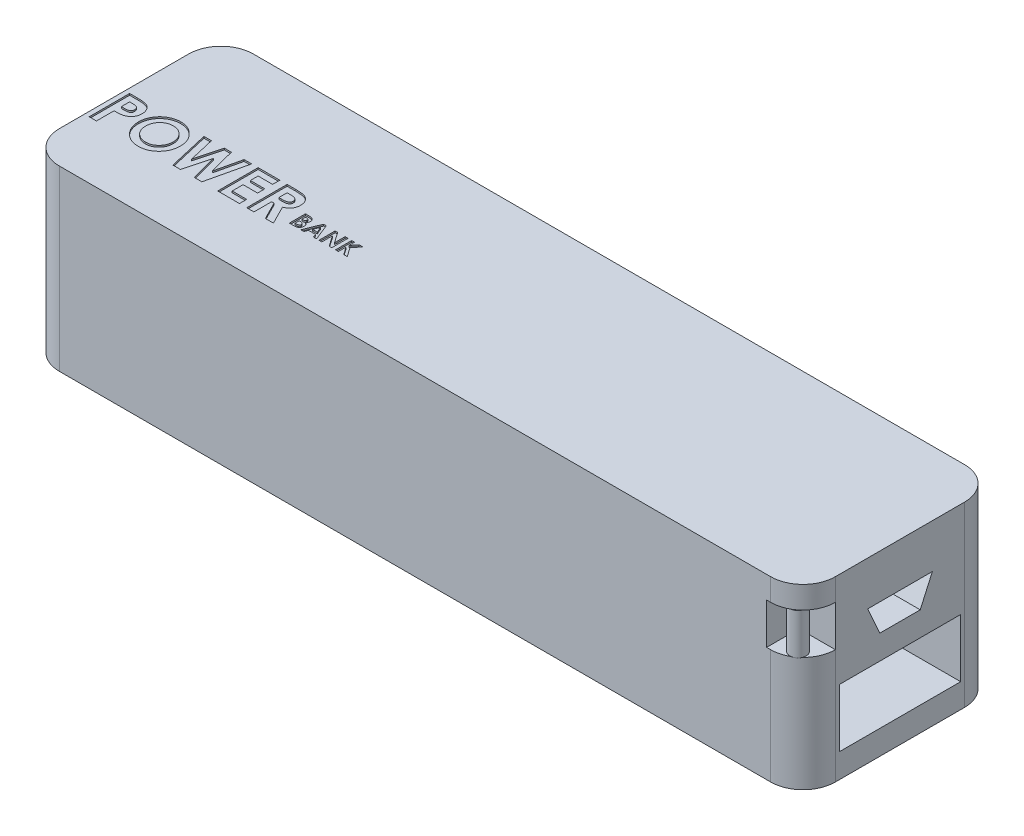
from build123d import *

# Parameters (mm, degrees)
BOSS_EXTRUDE1_DEPTH = 22
CUT_EXTRUDE1_DEPTH  = 0.2
CUT_EXTRUDE2_DEPTH  = 0.2
SKETCH4_W           = 15
SKETCH4_H           = 7.2
CUT_EXTRUDE3_DEPTH  = 10
CUT_EXTRUDE4_DEPTH  = 10
SKETCH6_W           = 4.5
SKETCH6_H           = 5.070723084
CUT_EXTRUDE5_DEPTH  = 4
SKETCH7_R           = 1
BOSS_EXTRUDE3_DEPTH = 5.070723


with BuildPart() as part:
    # Sketch1 → Boss-Extrude1 (new body)
    with BuildSketch(Plane(origin=(0, 0, 0), x_dir=(1, 0, 0), z_dir=(0, 1, 0))):
        with BuildLine():
            Line((-44, -12), (44, -12))
            ThreePointArc((44, -12), (46.828427125, -10.828427125), (48, -8))
            Line((48, -8), (48, 8))
            ThreePointArc((48, 8), (46.828427125, 10.828427125), (44, 12))
            Line((44, 12), (-44, 12))
            ThreePointArc((-44, 12), (-46.828427125, 10.828427125), (-48, 8))
            Line((-48, 8), (-48, -8))
            ThreePointArc((-48, -8), (-46.828427125, -10.828427125), (-44, -12))
        make_face()
    extrude(amount=BOSS_EXTRUDE1_DEPTH)

    # Sketch2 → Cut-Extrude1 (cut)
    with BuildSketch(Plane(origin=(0, 22, 0), x_dir=(1, 0, 0), z_dir=(0, 1, 0))):
        with BuildLine():
            Line((-47.423076923, 0.119421622), (-46.421474359, 0.119421622))
            add(Edge.make_bspline(
                [(-46.421474359, 0.119421622), (-46.356030947, 0.119128683), (-46.229776887, 0.118563543), (-46.047708145, 0.111710468), (-45.879740816, 0.099429341), (-45.725913491, 0.084251809), (-45.586289418, 0.062973501), (-45.460693748, 0.038579586), (-45.349100415, 0.008860699), (-45.250251039, -0.026415209), (-45.161536917, -0.068004126), (-45.077584745, -0.112299291), (-45.000291851, -0.165164009), (-44.925757029, -0.220900743), (-44.858241563, -0.284834005), (-44.793533435, -0.352708941), (-44.73437321, -0.427217416), (-44.680486762, -0.507457526), (-44.63160345, -0.591946776), (-44.588895719, -0.680836207), (-44.554253599, -0.774266478), (-44.525193168, -0.871633202), (-44.501851546, -0.972932135), (-44.48631462, -1.078786274), (-44.475761158, -1.188456505), (-44.474829961, -1.263098134), (-44.474358974, -1.300850814)],
                knots=[0, 0, 0, 0, 0.000196324, 0.000378751, 0.00054645, 0.000701527, 0.000842329, 0.000970009, 0.001085176, 0.001188463, 0.001284371, 0.001378936, 0.001472831, 0.001564984, 0.001657831, 0.001751361, 0.001846154, 0.001942828, 0.002041098, 0.002138763, 0.00223829, 0.002339695, 0.002443447, 0.002549829, 0.002660459, 0.00277368, 0.00277368, 0.00277368, 0.00277368], degree=3))
            add(Edge.make_bspline(
                [(-44.474358974, -1.300850814), (-44.475040433, -1.342615706), (-44.476379582, -1.424688851), (-44.489507563, -1.544998012), (-44.511934301, -1.659701904), (-44.541244875, -1.769767846), (-44.582116386, -1.87338501), (-44.628810168, -1.973025731), (-44.686258331, -2.065896392), (-44.75190204, -2.15315869), (-44.82359246, -2.235522111), (-44.903031518, -2.310608566), (-44.988705071, -2.378929917), (-45.080117185, -2.441202178), (-45.17761105, -2.49729973), (-45.281116318, -2.547747868), (-45.391339782, -2.590933105), (-45.468096086, -2.613518634), (-45.507011218, -2.624969404)],
                knots=[0, 0, 0, 0, 0.000125264, 0.00024616, 0.000362449, 0.000475684, 0.000587289, 0.000696151, 0.000805404, 0.000914178, 0.001023477, 0.001132583, 0.00124161, 0.0013519, 0.001464084, 0.001578762, 0.001697057, 0.00181871, 0.00181871, 0.00181871, 0.00181871], degree=3))
            add(Edge.make_bspline(
                [(-45.507011218, -2.624969404), (-45.532642962, -2.631346624), (-45.588169574, -2.645161734), (-45.680050865, -2.659187539), (-45.785934406, -2.672083405), (-45.906162588, -2.68316584), (-46.040804725, -2.690699313), (-46.189730447, -2.696582621), (-46.353007247, -2.700860393), (-46.466543477, -2.701012188), (-46.525641026, -2.701091199)],
                knots=[0, 0, 0, 0, 7.9203e-05, 0.000171578, 0.000278544, 0.00039924, 0.000533694, 0.000683053, 0.000846364, 0.00102365, 0.00102365, 0.00102365, 0.00102365], degree=3))
            Line((-46.525641026, -2.701091199), (-46.525641026, -4.880578378))
            Line((-46.525641026, -4.880578378), (-47.423076923, -4.880578378))
            Line((-47.423076923, -4.880578378), (-47.423076923, 0.119421622))
        make_face()
        with BuildLine():
            Line((-46.525641026, -1.803655302), (-46.208133013, -1.803655302))
            add(Edge.make_bspline(
                [(-46.208133013, -1.803655302), (-46.150357417, -1.803288959), (-46.044049463, -1.802614884), (-45.898870338, -1.792867369), (-45.782201601, -1.777980944), (-45.690031132, -1.756630368), (-45.617253816, -1.724228041), (-45.554487938, -1.686744651), (-45.500652042, -1.639347933), (-45.45403808, -1.585189073), (-45.416771622, -1.522957828), (-45.390929274, -1.453667514), (-45.374142594, -1.378773994), (-45.372592188, -1.326653061), (-45.371794872, -1.299849212)],
                knots=[0, 0, 0, 0, 0.000173303, 0.000318881, 0.000436167, 0.000526049, 0.000601409, 0.000674244, 0.000744535, 0.000815585, 0.000887902, 0.00096082, 0.001036651, 0.001116936, 0.001116936, 0.001116936, 0.001116936], degree=3))
            add(Edge.make_bspline(
                [(-45.371794872, -1.299849212), (-45.372583986, -1.276431038), (-45.374115058, -1.230994151), (-45.385362726, -1.165417452), (-45.403288275, -1.104286441), (-45.429261705, -1.04823955), (-45.4628392, -0.997372012), (-45.503776962, -0.951703865), (-45.551549679, -0.910257087), (-45.588433009, -0.888318675), (-45.607171474, -0.87717293)],
                knots=[0, 0, 0, 0, 7.0227e-05, 0.000136256, 0.000198999, 0.000260839, 0.000320843, 0.000381148, 0.000444376, 0.000509672, 0.000509672, 0.000509672, 0.000509672], degree=3))
            add(Edge.make_bspline(
                [(-45.607171474, -0.87717293), (-45.623044036, -0.86914572), (-45.656649503, -0.852150472), (-45.713882871, -0.832392253), (-45.779929303, -0.815724019), (-45.855234688, -0.801889546), (-45.939498611, -0.791152558), (-46.032706038, -0.782941448), (-46.134994131, -0.779639441), (-46.20612938, -0.778570939), (-46.243189103, -0.778014276)],
                knots=[0, 0, 0, 0, 5.3311e-05, 0.000112871, 0.000181134, 0.000257552, 0.000342405, 0.000435898, 0.00053814, 0.000649336, 0.000649336, 0.000649336, 0.000649336], degree=3))
            Line((-46.243189103, -0.778014276), (-46.525641026, -0.778014276))
            Line((-46.525641026, -0.778014276), (-46.525641026, -1.803655302))
        make_face(mode=Mode.SUBTRACT)
        with BuildLine():
            add(Edge.make_bspline(
                [(-41.227163462, 0.24762675), (-41.140232334, 0.245375947), (-40.968610598, 0.240932353), (-40.716216956, 0.203891528), (-40.472989015, 0.143538815), (-40.239036762, 0.059644178), (-40.014945985, -0.050064676), (-39.799926243, -0.182477429), (-39.594747724, -0.340093291), (-39.401512935, -0.519235346), (-39.222929139, -0.714044508), (-39.068186176, -0.923791205), (-38.936227054, -1.14304069), (-38.82685898, -1.372380448), (-38.743554836, -1.613398766), (-38.685096872, -1.86486677), (-38.647540526, -2.126712918), (-38.643220968, -2.304994455), (-38.641025641, -2.395602417)],
                knots=[0, 0, 0, 0, 0.000260694, 0.000514669, 0.000763423, 0.0010115, 0.001258772, 0.00151061, 0.001767833, 0.002033636, 0.002300239, 0.002559459, 0.002814199, 0.003066888, 0.003320296, 0.003577575, 0.003840476, 0.004112177, 0.004112177, 0.004112177, 0.004112177], degree=3))
            add(Edge.make_bspline(
                [(-38.641025641, -2.395602417), (-38.64336357, -2.485189436), (-38.647970533, -2.661723532), (-38.683563657, -2.921156665), (-38.743006061, -3.169930922), (-38.824897302, -3.40860941), (-38.932281852, -3.636036051), (-39.061667627, -3.853662933), (-39.216468873, -4.059470427), (-39.39103938, -4.253348088), (-39.583226357, -4.429333667), (-39.786782876, -4.584420654), (-40.000769038, -4.715835515), (-40.224871635, -4.823518054), (-40.459571244, -4.907086507), (-40.704288129, -4.966050124), (-40.959007147, -5.001883504), (-41.132228432, -5.006460375), (-41.220152244, -5.008783507)],
                knots=[0, 0, 0, 0, 0.000268698, 0.000529479, 0.000783835, 0.001035021, 0.001285045, 0.001537037, 0.001793248, 0.002056349, 0.002318643, 0.002573855, 0.002822938, 0.003070676, 0.003318415, 0.003568875, 0.003824694, 0.00408839, 0.00408839, 0.00408839, 0.00408839], degree=3))
            add(Edge.make_bspline(
                [(-41.220152244, -5.008783507), (-41.312110008, -5.006699543), (-41.492794446, -5.002604838), (-41.75722693, -4.963666068), (-42.010576099, -4.905010677), (-42.250713673, -4.817470653), (-42.480085249, -4.708038262), (-42.697005566, -4.573265712), (-42.901401725, -4.413375724), (-43.092101276, -4.232463142), (-43.264875531, -4.034505096), (-43.4173827, -3.825379975), (-43.546025881, -3.606685311), (-43.65080978, -3.378318751), (-43.733417196, -3.141699537), (-43.791687343, -2.89538659), (-43.826108909, -2.639970657), (-43.830903633, -2.466487049), (-43.833333333, -2.378575173)],
                knots=[0, 0, 0, 0, 0.000275703, 0.000541718, 0.000800204, 0.001054613, 0.00130683, 0.001561426, 0.001819079, 0.002084056, 0.002348822, 0.002606265, 0.00285947, 0.00310865, 0.00335889, 0.003610091, 0.003866767, 0.004130463, 0.004130463, 0.004130463, 0.004130463], degree=3))
            add(Edge.make_bspline(
                [(-43.833333333, -2.378575173), (-43.832570753, -2.319432665), (-43.831055249, -2.20189653), (-43.812799408, -2.027713976), (-43.786516245, -1.856931232), (-43.747644694, -1.69022921), (-43.700425694, -1.526431907), (-43.63924681, -1.367063986), (-43.569608684, -1.210422962), (-43.48824309, -1.05835896), (-43.397772417, -0.912271097), (-43.299060858, -0.772848493), (-43.191860203, -0.641776974), (-43.076515783, -0.518195189), (-42.952630104, -0.402915452), (-42.821832754, -0.294305817), (-42.681587027, -0.195251343), (-42.534962462, -0.103332921), (-42.382785693, -0.020212686), (-42.225676219, 0.050536772), (-42.066870805, 0.112321068), (-41.904248025, 0.161083967), (-41.739550671, 0.200800838), (-41.571019285, 0.227066286), (-41.400176454, 0.245321622), (-41.284971324, 0.24685655), (-41.227163462, 0.24762675)],
                knots=[0, 0, 0, 0, 0.000177354, 0.000352463, 0.00052487, 0.000695436, 0.000865629, 0.001035846, 0.001207105, 0.001379616, 0.001552781, 0.001722309, 0.001891725, 0.002060382, 0.002229038, 0.002399089, 0.002570014, 0.002743708, 0.00291805, 0.003089722, 0.003260295, 0.003428856, 0.003598674, 0.003768114, 0.003940232, 0.004113581, 0.004113581, 0.004113581, 0.004113581], degree=3))
        make_face()
        with BuildLine():
            add(Edge.make_bspline(
                [(-41.241185897, -0.649809148), (-41.299690535, -0.651378958), (-41.415155278, -0.654477137), (-41.584521028, -0.678081065), (-41.747118129, -0.715779222), (-41.902045242, -0.77038454), (-42.049973833, -0.839883253), (-42.191166134, -0.924032521), (-42.323666924, -1.025724883), (-42.449242973, -1.139500928), (-42.562680269, -1.26627359), (-42.662905699, -1.402132057), (-42.746778241, -1.546849448), (-42.81702202, -1.699081373), (-42.869900018, -1.860539638), (-42.90756343, -2.029959525), (-42.931365301, -2.207632952), (-42.934365556, -2.328752696), (-42.935897436, -2.390594404)],
                knots=[0, 0, 0, 0, 0.000175464, 0.000346295, 0.000511984, 0.000675438, 0.000838087, 0.001001615, 0.001167482, 0.001338346, 0.00150928, 0.001676958, 0.001843934, 0.002010219, 0.002179038, 0.002352535, 0.002530316, 0.002715786, 0.002715786, 0.002715786, 0.002715786], degree=3))
            add(Edge.make_bspline(
                [(-42.935897436, -2.390594404), (-42.933866397, -2.459128928), (-42.929885897, -2.593445238), (-42.901878615, -2.789382252), (-42.853960943, -2.974425316), (-42.784768758, -3.14766941), (-42.698952294, -3.311038282), (-42.592381867, -3.462529612), (-42.466783411, -3.603050461), (-42.370023379, -3.685092386), (-42.320913462, -3.726732225)],
                knots=[0, 0, 0, 0, 0.000205573, 0.000402888, 0.000592382, 0.000777632, 0.000961338, 0.00114473, 0.001331968, 0.001524943, 0.001524943, 0.001524943, 0.001524943], degree=3))
            add(Edge.make_bspline(
                [(-42.320913462, -3.726732225), (-42.280683064, -3.757494138), (-42.201128666, -3.818324894), (-42.074142526, -3.896291987), (-41.943371807, -3.963117563), (-41.807829679, -4.017111838), (-41.667802401, -4.059582827), (-41.523309174, -4.089324562), (-41.374554734, -4.107990073), (-41.27396001, -4.110220956), (-41.223157051, -4.111347609)],
                knots=[0, 0, 0, 0, 0.000151848, 0.000300274, 0.000446302, 0.000591935, 0.000737374, 0.000884702, 0.001034031, 0.001186393, 0.001186393, 0.001186393, 0.001186393], degree=3))
            add(Edge.make_bspline(
                [(-41.223157051, -4.111347609), (-41.165658402, -4.109764488), (-41.052528002, -4.106649648), (-40.886315087, -4.083336297), (-40.727078066, -4.04388169), (-40.573828383, -3.989755388), (-40.42700794, -3.919384059), (-40.287334289, -3.832624745), (-40.154562545, -3.730542736), (-40.029146478, -3.615272562), (-39.914510265, -3.488000504), (-39.814493985, -3.351417382), (-39.727954715, -3.208532531), (-39.659171657, -3.057323633), (-39.604204569, -2.899218029), (-39.566994455, -2.733515504), (-39.542991513, -2.560899146), (-39.539990412, -2.443427614), (-39.538461538, -2.383583186)],
                knots=[0, 0, 0, 0, 0.000172462, 0.000339324, 0.000502327, 0.000663893, 0.000826066, 0.000989781, 0.001156255, 0.001327796, 0.001500144, 0.001669222, 0.001834983, 0.002000357, 0.00216665, 0.002336241, 0.002509057, 0.002688523, 0.002688523, 0.002688523, 0.002688523], degree=3))
            add(Edge.make_bspline(
                [(-39.538461538, -2.383583186), (-39.540043312, -2.324082881), (-39.543156791, -2.206965603), (-39.566511175, -2.034793041), (-39.605715571, -1.869822043), (-39.660004408, -1.711783197), (-39.729328379, -1.560521563), (-39.815054501, -1.416569069), (-39.916881973, -1.28006488), (-40.032467241, -1.151939221), (-40.158274701, -1.034199948), (-40.29334158, -0.932023661), (-40.433888555, -0.843235717), (-40.58314046, -0.773682827), (-40.738043725, -0.718270186), (-40.899543578, -0.677463523), (-41.06825171, -0.654642956), (-41.18302734, -0.651434779), (-41.241185897, -0.649809148)],
                knots=[0, 0, 0, 0, 0.000178465, 0.000351282, 0.000520125, 0.000686418, 0.000851792, 0.001018414, 0.001188087, 0.00136185, 0.001535486, 0.00170416, 0.001869254, 0.002033236, 0.002197025, 0.002362213, 0.002532052, 0.002706515, 0.002706515, 0.002706515, 0.002706515], degree=3))
        make_face(mode=Mode.SUBTRACT)
        Polygon((-38.224358974, 0.119421622), (-37.297876603, 0.119421622), (-36.557692308, -3.07268575), (-35.709334936, 0.119421622), (-34.836939103, 0.119421622), (-33.993589744, -3.07268575), (-33.255408654, 0.119421622), (-32.326923077, 0.119421622), (-33.483774038, -4.880578378), (-34.421274038, -4.880578378), (-35.275641026, -1.648406904), (-36.135016026, -4.880578378), (-37.065504808, -4.880578378), align=None)
        Polygon((-31.525641026, 0.119421622), (-28.833333333, 0.119421622), (-28.833333333, -0.778014276), (-30.628205128, -0.778014276), (-30.628205128, -1.739552737), (-28.833333333, -1.739552737), (-28.833333333, -2.636988635), (-30.628205128, -2.636988635), (-30.628205128, -3.983142481), (-28.833333333, -3.983142481), (-28.833333333, -4.880578378), (-31.525641026, -4.880578378), align=None)
        with BuildLine():
            Line((-27.935897436, 0.119421622), (-26.890224359, 0.119421622))
            add(Edge.make_bspline(
                [(-26.890224359, 0.119421622), (-26.821105687, 0.11917629), (-26.688171011, 0.118704448), (-26.496486469, 0.111260034), (-26.320397856, 0.100900521), (-26.159644457, 0.08509163), (-26.014295045, 0.06413095), (-25.884203946, 0.039421778), (-25.769374963, 0.011260378), (-25.668839672, -0.023830948), (-25.578111542, -0.063413431), (-25.493540312, -0.10889443), (-25.413260214, -0.1597675), (-25.337807834, -0.217371248), (-25.266527472, -0.280669398), (-25.199284655, -0.349725666), (-25.137029585, -0.425125619), (-25.080147749, -0.506392826), (-25.028304534, -0.591884064), (-24.982486006, -0.681716713), (-24.945226302, -0.775953247), (-24.91230336, -0.873231742), (-24.888590031, -0.974942815), (-24.872097758, -1.080096291), (-24.86002276, -1.189062321), (-24.859328506, -1.263089004), (-24.858974359, -1.300850814)],
                knots=[0, 0, 0, 0, 0.000207341, 0.000398776, 0.000575402, 0.000736458, 0.000883205, 0.001015799, 0.001133619, 0.001237515, 0.001334841, 0.001430288, 0.001525314, 0.001619667, 0.00171474, 0.001811071, 0.001908535, 0.00200774, 0.002108399, 0.002208289, 0.002309842, 0.002412147, 0.002516126, 0.002622664, 0.002731397, 0.002844618, 0.002844618, 0.002844618, 0.002844618], degree=3))
            add(Edge.make_bspline(
                [(-24.858974359, -1.300850814), (-24.859894305, -1.34026547), (-24.861698151, -1.417550425), (-24.871414649, -1.53107572), (-24.889173355, -1.639688782), (-24.916071499, -1.743071605), (-24.946987421, -1.842510909), (-24.988097668, -1.936171975), (-25.034494644, -2.02541697), (-25.089598977, -2.108983488), (-25.150073291, -2.188727708), (-25.220403645, -2.261594335), (-25.296033714, -2.331499672), (-25.381214939, -2.394065088), (-25.472192452, -2.453521029), (-25.570773881, -2.507403945), (-25.67631585, -2.557068329), (-25.750517081, -2.58476462), (-25.788461538, -2.598927737)],
                knots=[0, 0, 0, 0, 0.000118257, 0.00023188, 0.000341546, 0.000447947, 0.000552157, 0.000653556, 0.000754365, 0.000853544, 0.000953514, 0.001054124, 0.001156939, 0.001262107, 0.001370733, 0.001482805, 0.001598862, 0.00172032, 0.00172032, 0.00172032, 0.00172032], degree=3))
            Line((-25.788461538, -2.598927737), (-24.634615385, -4.880578378))
            Line((-24.634615385, -4.880578378), (-25.632211538, -4.880578378))
            Line((-25.632211538, -4.880578378), (-26.733974359, -2.701091199))
            Line((-26.733974359, -2.701091199), (-27.038461538, -2.701091199))
            Line((-27.038461538, -2.701091199), (-27.038461538, -4.880578378))
            Line((-27.038461538, -4.880578378), (-27.935897436, -4.880578378))
            Line((-27.935897436, -4.880578378), (-27.935897436, 0.119421622))
        make_face()
        with BuildLine():
            Line((-27.038461538, -1.803655302), (-26.688902244, -1.803655302))
            add(Edge.make_bspline(
                [(-26.688902244, -1.803655302), (-26.646165714, -1.803173974), (-26.564334443, -1.802252335), (-26.446650327, -1.797977393), (-26.339765084, -1.787676893), (-26.243219712, -1.774662597), (-26.156528404, -1.759635713), (-26.080464415, -1.738101276), (-26.013855716, -1.715026581), (-25.957491621, -1.686350721), (-25.909335435, -1.653740048), (-25.867755649, -1.616693514), (-25.833363205, -1.573816867), (-25.805056469, -1.526275311), (-25.783036906, -1.473648352), (-25.766964312, -1.416513714), (-25.757982109, -1.354220562), (-25.756948676, -1.311229804), (-25.756410256, -1.288831584)],
                knots=[0, 0, 0, 0, 0.000128221, 0.000245515, 0.000353154, 0.000450185, 0.000537801, 0.000616775, 0.000687116, 0.000748932, 0.000805883, 0.000861198, 0.000915322, 0.000970118, 0.001026671, 0.001085968, 0.001147728, 0.001214902, 0.001214902, 0.001214902, 0.001214902], degree=3))
            add(Edge.make_bspline(
                [(-25.756410256, -1.288831584), (-25.757428188, -1.262332853), (-25.759427725, -1.210281008), (-25.77926935, -1.135344603), (-25.810852931, -1.065985833), (-25.85414537, -1.002518079), (-25.908666569, -0.946877863), (-25.971233946, -0.897830571), (-26.043197856, -0.859047642), (-26.109831021, -0.833466834), (-26.170451627, -0.818161574), (-26.225159811, -0.806756229), (-26.288512218, -0.798672933), (-26.360556674, -0.79009916), (-26.441109537, -0.784539502), (-26.530609868, -0.780482059), (-26.628800622, -0.77882196), (-26.697248903, -0.778291256), (-26.732972756, -0.778014276)],
                knots=[0, 0, 0, 0, 7.9354e-05, 0.000155877, 0.00023073, 0.000307128, 0.000385047, 0.000463582, 0.000544718, 0.000629358, 0.000676973, 0.000732171, 0.000796904, 0.000868468, 0.00094982, 0.001039053, 0.00113723, 0.001244406, 0.001244406, 0.001244406, 0.001244406], degree=3))
            Line((-26.732972756, -0.778014276), (-27.038461538, -0.778014276))
            Line((-27.038461538, -0.778014276), (-27.038461538, -1.803655302))
        make_face(mode=Mode.SUBTRACT)
    extrude(amount=-CUT_EXTRUDE1_DEPTH, mode=Mode.SUBTRACT)

    # Sketch3 → Cut-Extrude2 (cut)
    with BuildSketch(Plane(origin=(0, 22, 0), x_dir=(1, 0, 0), z_dir=(0, 1, 0))):
        with BuildLine():
            Line((-23.649577928, -3.896093236), (-23.649577928, -1.896093236))
            Line((-23.649577928, -1.896093236), (-23.329065108, -1.896093236))
            add(Edge.make_bspline(
                [(-23.329065108, -1.896093236), (-23.306627206, -1.896090675), (-23.263210292, -1.89608572), (-23.200571016, -1.898285406), (-23.142478377, -1.901130946), (-23.08911725, -1.904314443), (-23.040396808, -1.909800246), (-22.996391141, -1.915581682), (-22.957012324, -1.922553738), (-22.932666541, -1.928807888), (-22.921212544, -1.931750287)],
                knots=[0, 0, 0, 0, 6.7309e-05, 0.000130241, 0.000188002, 0.000241809, 0.000290565, 0.000335044, 0.000374963, 0.000410431, 0.000410431, 0.000410431, 0.000410431], degree=3))
            add(Edge.make_bspline(
                [(-22.921212544, -1.931750287), (-22.906172282, -1.935900594), (-22.876658459, -1.944044829), (-22.834385247, -1.960492463), (-22.794283209, -1.978775174), (-22.756401308, -1.999632328), (-22.720972153, -2.02331573), (-22.688130389, -2.050013337), (-22.657167699, -2.078653509), (-22.629183498, -2.110034439), (-22.603890391, -2.143194205), (-22.581915216, -2.178124118), (-22.562821605, -2.214290077), (-22.547541715, -2.252147205), (-22.536028606, -2.291521162), (-22.527607965, -2.332243813), (-22.52215025, -2.374444016), (-22.521634567, -2.403154193), (-22.5213728, -2.417727851)],
                knots=[0, 0, 0, 0, 4.6779e-05, 9.1795e-05, 0.000135895, 0.000178934, 0.000221381, 0.000263553, 0.000305788, 0.000347777, 0.000389524, 0.000430761, 0.00047144, 0.000512061, 0.000553007, 0.000594337, 0.000636725, 0.000680424, 0.000680424, 0.000680424, 0.000680424], degree=3))
            add(Edge.make_bspline(
                [(-22.5213728, -2.417727851), (-22.522057243, -2.436451177), (-22.523404486, -2.473305742), (-22.532010762, -2.52743843), (-22.548148872, -2.578601601), (-22.569265196, -2.627738173), (-22.597976795, -2.674664866), (-22.634434973, -2.719359367), (-22.678049226, -2.763197888), (-22.711503766, -2.789476124), (-22.728904851, -2.803144518)],
                knots=[0, 0, 0, 0, 5.6181e-05, 0.000110586, 0.000163812, 0.000216736, 0.000270674, 0.000328239, 0.00038943, 0.000455759, 0.000455759, 0.000455759, 0.000455759], degree=3))
            add(Edge.make_bspline(
                [(-22.728904851, -2.803144518), (-22.714803846, -2.810342959), (-22.687155677, -2.82445711), (-22.647903399, -2.84765656), (-22.611560075, -2.872332118), (-22.577962751, -2.897987301), (-22.54781617, -2.92570967), (-22.51987553, -2.953901823), (-22.495519276, -2.984179054), (-22.473739179, -3.015462225), (-22.454808273, -3.04820432), (-22.438321542, -3.082350044), (-22.424395791, -3.118016047), (-22.412603105, -3.155020817), (-22.403808117, -3.193491635), (-22.398073598, -3.233442258), (-22.393682891, -3.274736434), (-22.393341336, -3.302864996), (-22.393167672, -3.317166954)],
                knots=[0, 0, 0, 0, 4.7489e-05, 9.3113e-05, 0.000136672, 0.000179225, 0.000219785, 0.000259451, 0.000298182, 0.000336191, 0.00037371, 0.000411519, 0.000449834, 0.000488481, 0.00052794, 0.000568056, 0.000609516, 0.000652401, 0.000652401, 0.000652401, 0.000652401], degree=3))
            add(Edge.make_bspline(
                [(-22.393167672, -3.317166954), (-22.394294634, -3.344482875), (-22.39651869, -3.398390736), (-22.412779902, -3.477539857), (-22.440971677, -3.552580403), (-22.478827416, -3.623214129), (-22.525472971, -3.687396307), (-22.579101983, -3.743619337), (-22.63917453, -3.791210884), (-22.694598716, -3.823331486), (-22.742536272, -3.844887414), (-22.782242054, -3.858214648), (-22.824885222, -3.870560977), (-22.871246896, -3.879230824), (-22.920486604, -3.887166422), (-22.973084434, -3.892066024), (-23.028942083, -3.895386364), (-23.067307531, -3.895852848), (-23.087077928, -3.896093236)],
                knots=[0, 0, 0, 0, 8.1923e-05, 0.000161675, 0.000241156, 0.000321638, 0.000401375, 0.00047845, 0.000554036, 0.000630516, 0.000669975, 0.000711533, 0.000756055, 0.000803041, 0.000852904, 0.000905646, 0.000961427, 0.001020734, 0.001020734, 0.001020734, 0.001020734], degree=3))
            Line((-23.087077928, -3.896093236), (-23.649577928, -3.896093236))
        make_face()
        with BuildLine():
            Line((-23.290603569, -2.255067595), (-23.290603569, -2.690965031))
            Line((-23.290603569, -2.690965031), (-23.195251005, -2.690965031))
            add(Edge.make_bspline(
                [(-23.195251005, -2.690965031), (-23.182291735, -2.690852021), (-23.157274648, -2.690633863), (-23.12114012, -2.687824057), (-23.087540844, -2.683030355), (-23.056604256, -2.676341935), (-23.028042169, -2.667848616), (-23.002037047, -2.657629324), (-22.978703229, -2.645160677), (-22.95159473, -2.626588078), (-22.922939091, -2.599257666), (-22.897713855, -2.559773223), (-22.882856359, -2.514366265), (-22.881201635, -2.482341761), (-22.880347159, -2.465804775)],
                knots=[0, 0, 0, 0, 3.887e-05, 7.5037e-05, 0.000108636, 0.00014062, 0.000169899, 0.000197947, 0.000224295, 0.000249077, 0.000296395, 0.000341964, 0.000388335, 0.000437847, 0.000437847, 0.000437847, 0.000437847], degree=3))
            add(Edge.make_bspline(
                [(-22.880347159, -2.465804775), (-22.881030896, -2.450315139), (-22.882352874, -2.42036655), (-22.897312462, -2.378316065), (-22.920547659, -2.341050729), (-22.947980076, -2.315545654), (-22.973813027, -2.29812644), (-22.995932785, -2.286656629), (-23.02021088, -2.276388972), (-23.047117311, -2.26853807), (-23.076498426, -2.262647031), (-23.108211505, -2.258320767), (-23.142311265, -2.255376129), (-23.165864042, -2.255172646), (-23.178023441, -2.255067595)],
                knots=[0, 0, 0, 0, 4.6284e-05, 8.9488e-05, 0.000132169, 0.000176944, 0.000200613, 0.000225523, 0.000251565, 0.000279578, 0.000309436, 0.000341392, 0.000375562, 0.000412029, 0.000412029, 0.000412029, 0.000412029], degree=3))
            Line((-23.178023441, -2.255067595), (-23.290603569, -2.255067595))
        make_face(mode=Mode.SUBTRACT)
        with BuildLine():
            Line((-23.290603569, -3.024298364), (-23.290603569, -3.537118877))
            Line((-23.290603569, -3.537118877), (-23.187238185, -3.537118877))
            add(Edge.make_bspline(
                [(-23.187238185, -3.537118877), (-23.166802717, -3.53700213), (-23.127512979, -3.536777669), (-23.0712305, -3.534065649), (-23.020055655, -3.52917771), (-22.97412404, -3.523075512), (-22.9333653, -3.514807988), (-22.897917212, -3.504296891), (-22.867293648, -3.492732854), (-22.841678231, -3.478449895), (-22.820751903, -3.461828072), (-22.801868086, -3.44484017), (-22.786471398, -3.425243021), (-22.774289251, -3.403877874), (-22.763745625, -3.381275457), (-22.757386454, -3.356553152), (-22.752544804, -3.33044367), (-22.752278355, -3.312384306), (-22.752142031, -3.303144518)],
                knots=[0, 0, 0, 0, 6.1303e-05, 0.000117863, 0.000168971, 0.000215489, 0.000256819, 0.000293582, 0.000326317, 0.000354842, 0.000381126, 0.000406353, 0.000430881, 0.00045548, 0.00048005, 0.000505421, 0.000531833, 0.000559503, 0.000559503, 0.000559503, 0.000559503], degree=3))
            add(Edge.make_bspline(
                [(-22.752142031, -3.303144518), (-22.752442665, -3.292578675), (-22.75302822, -3.271999255), (-22.757810454, -3.241920236), (-22.766501336, -3.213839476), (-22.777447926, -3.187038912), (-22.792680687, -3.162478097), (-22.810784304, -3.139307076), (-22.832658094, -3.11831049), (-22.857256447, -3.098218388), (-22.88594799, -3.080626663), (-22.918746185, -3.065362726), (-22.955829209, -3.052614848), (-22.997311931, -3.042464979), (-23.043012494, -3.033850926), (-23.093264462, -3.028707385), (-23.147649318, -3.024881908), (-23.185360663, -3.024497299), (-23.20486639, -3.024298364)],
                knots=[0, 0, 0, 0, 3.1691e-05, 6.1726e-05, 9.1006e-05, 0.000119729, 0.000148313, 0.000177408, 0.000207722, 0.000239069, 0.000272534, 0.00030838, 0.000347405, 0.000389965, 0.000436407, 0.0004868, 0.000541407, 0.000599912, 0.000599912, 0.000599912, 0.000599912], degree=3))
            Line((-23.20486639, -3.024298364), (-23.290603569, -3.024298364))
        make_face(mode=Mode.SUBTRACT)
        Polygon((-21.418408056, -1.896093236), (-21.085475364, -1.896093236), (-20.277783056, -3.896093236), (-20.661196518, -3.896093236), (-20.816645236, -3.485836826), (-21.688039467, -3.485836826), (-21.843488185, -3.896093236), (-22.226501005, -3.896093236), align=None)
        Polygon((-21.252142031, -2.432551569), (-21.551821518, -3.126862467), (-20.952462544, -3.126862467), align=None, mode=Mode.SUBTRACT)
        Polygon((-19.982911262, -1.896093236), (-19.659593954, -1.896093236), (-18.752142031, -3.212199005), (-18.752142031, -1.896093236), (-18.393167672, -1.896093236), (-18.393167672, -3.896093236), (-18.718888826, -3.896093236), (-19.623936903, -2.583993877), (-19.623936903, -3.896093236), (-19.982911262, -3.896093236), align=None)
        Polygon((-17.93162921, -1.896093236), (-17.572654851, -1.896093236), (-17.572654851, -2.600019518), (-17.005347159, -1.896093236), (-16.552222159, -1.896093236), (-17.264962544, -2.780708621), (-16.482911262, -3.896093236), (-16.915202928, -3.896093236), (-17.572654851, -2.958192595), (-17.572654851, -3.896093236), (-17.93162921, -3.896093236), align=None)
    extrude(amount=-CUT_EXTRUDE2_DEPTH, mode=Mode.SUBTRACT)

    # Sketch4 → Cut-Extrude3 (cut)
    with BuildSketch(Plane(origin=(48, 0, 0), x_dir=(0, 0, -1), z_dir=(1, 0, 0))):
        with Locations((0, 6.6)):
            Rectangle(SKETCH4_W, SKETCH4_H)
    extrude(amount=-CUT_EXTRUDE3_DEPTH, mode=Mode.SUBTRACT)

    # Sketch5 → Cut-Extrude4 (cut)
    with BuildSketch(Plane(origin=(48, 0, 0), x_dir=(0, 0, -1), z_dir=(1, 0, 0))):
        Polygon((-4, 16.55), (4, 16.55), (2.5, 13.2), (-2.5, 13.2), align=None)
    extrude(amount=-CUT_EXTRUDE4_DEPTH, mode=Mode.SUBTRACT)

    # Sketch6 → Cut-Extrude5 (cut)
    with BuildSketch(Plane.XY.offset(12)):
        with Locations((45.75, 16.71367768)):
            Rectangle(SKETCH6_W, SKETCH6_H)
    extrude(amount=-CUT_EXTRUDE5_DEPTH, mode=Mode.SUBTRACT)

    # Sketch7 → Boss-Extrude3 (add)
    with BuildSketch(Plane(origin=(0, 14.178316138, 0), x_dir=(1, 0, 0), z_dir=(0, 1, 0))):
        with Locations((45.8691676, -10.486553928)):
            Circle(SKETCH7_R)
    extrude(amount=BOSS_EXTRUDE3_DEPTH)


solid = part.part
